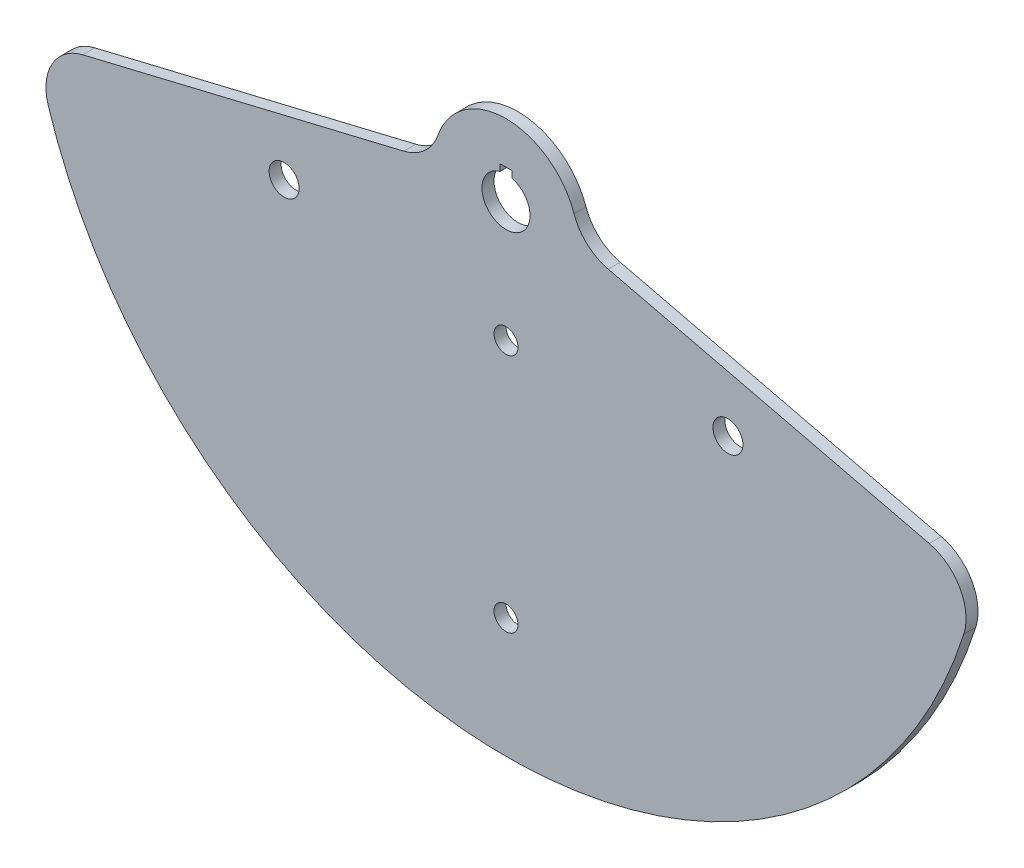
from build123d import *

# Parameters (mm, degrees)
SKETCH5_R               = 12.7
SKETCH5_R_2             = 7.9375
BOSS_EXTRUDE2_DEPTH     = 3.175
SKETCH8_W               = 6.35
SKETCH8_H               = 6.35
CUT_EXTRUDE1_DEPTH      = 4.175
CUT_EXTRUDE1_DEPTH_BACK = 4.175
SKETCH9_R               = 6.35
CUT_EXTRUDE2_DEPTH      = 4.175
CUT_EXTRUDE2_DEPTH_BACK = 4.175


with BuildPart() as part:
    # Sketch5 → Boss-Extrude2 (new body, symmetric)
    with BuildSketch(Plane.XY):
        with BuildLine():
            Line((-223.779910529, -44.577802506), (-54.04268144, -3.827499177))
            ThreePointArc((-54.04268144, -3.827499177), (-42.924981025, 2.041131203), (-35.983316209, 12.522418081))
            ThreePointArc((-35.983316209, 12.522418081), (0, 38.1), (35.983316209, 12.522418081))
            ThreePointArc((35.983316209, 12.522418081), (42.924981025, 2.041131203), (54.04268144, -3.827499177))
            Line((54.04268144, -3.827499177), (223.779910529, -44.577802506))
            ThreePointArc((223.779910529, -44.577802506), (239.972758508, -56.795566669), (242.055998097, -76.973331649))
            ThreePointArc((242.055998097, -76.973331649), (0, -254), (-242.055998097, -76.973331649))
            ThreePointArc((-242.055998097, -76.973331649), (-239.972758508, -56.795566669), (-223.779910529, -44.577802506))
        make_face()
        Circle(SKETCH5_R, mode=Mode.SUBTRACT)
        with Locations((-117.332700629, -48.60079591)):
            Circle(SKETCH5_R_2, mode=Mode.SUBTRACT)
        with Locations((117.332700629, -48.60079591)):
            Circle(SKETCH5_R_2, mode=Mode.SUBTRACT)
    extrude(amount=BOSS_EXTRUDE2_DEPTH, both=True)

    # Sketch8 → Cut-Extrude1 (cut, two sides)
    with BuildSketch(Plane.XY) as cut_extrude1_sk:
        with Locations((0, 12.7)):
            Rectangle(SKETCH8_W, SKETCH8_H)
    extrude(amount=CUT_EXTRUDE1_DEPTH, mode=Mode.SUBTRACT)
    extrude(cut_extrude1_sk.sketch, amount=-CUT_EXTRUDE1_DEPTH_BACK, mode=Mode.SUBTRACT)

    # Sketch9 → Cut-Extrude2 (cut, two sides)
    with BuildSketch(Plane.XY) as cut_extrude2_sk:
        with Locations((0, -63.5)):
            Circle(SKETCH9_R)
        with Locations((0, -190.5)):
            Circle(SKETCH9_R)
    extrude(amount=CUT_EXTRUDE2_DEPTH, mode=Mode.SUBTRACT)
    extrude(cut_extrude2_sk.sketch, amount=-CUT_EXTRUDE2_DEPTH_BACK, mode=Mode.SUBTRACT)


solid = part.part
